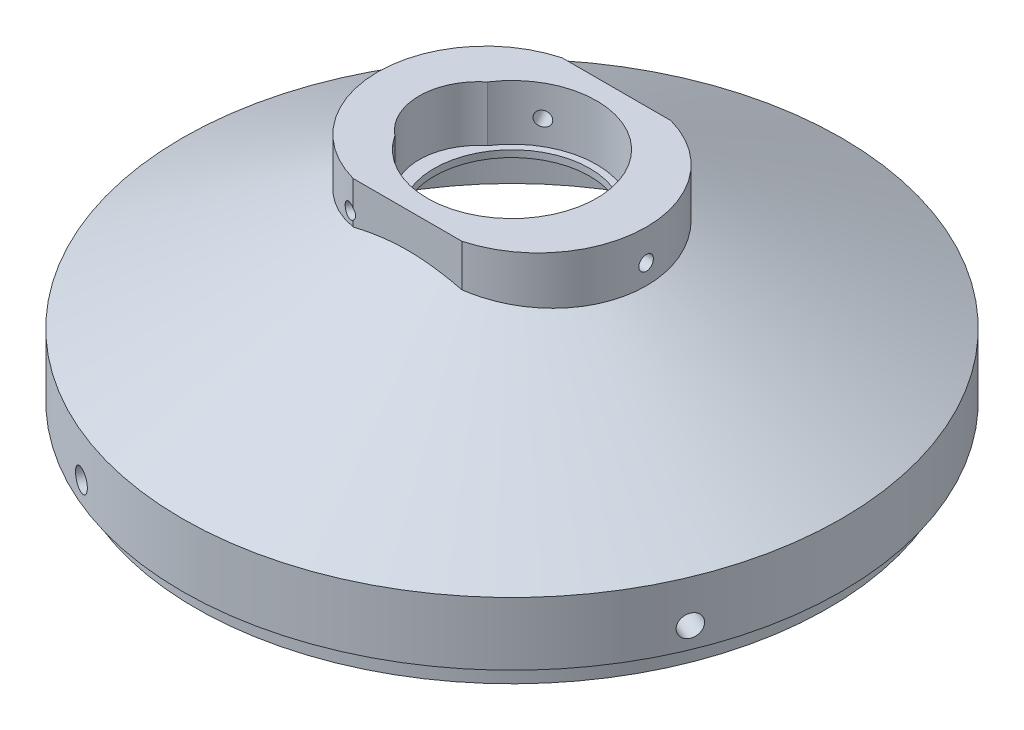
from build123d import *

# Parameters (mm, degrees)
SKETCH12_R          = 1.6425
CUT_EXTRUDE6_DEPTH  = 65.936179354
CUT_EXTRUDE7_REACH  = 38.04
SKETCH13_W          = 16.370705544
SKETCH13_H          = 2
BOSS_EXTRUDE1_REACH = 38.04
SKETCH14_R          = 12.75
CUT_EXTRUDE8_DEPTH  = 8.323317
SKETCH16_R          = 1.095
CUT_EXTRUDE9_DEPTH  = 50.7000001
CIRPATTERN2_COUNT   = 3
CIRPATTERN3_COUNT   = 4


with BuildPart() as part:
    # Sketch2 → Revolve1 (revolve)
    with BuildSketch(Plane.XY, mode=Mode.PRIVATE) as revolve1_sk:
        Polygon((49.7, 12.7), (49.7, 3.2004), (47.675, 3.2004), (47.675, 0), (44.7, 0), (44.7, 9.696683305), (12.75, 26.696683305), (11.73, 26.696683305), (11.73, 27.716683305), (12.75, 27.716683305), (12.75, 36.04), (17.75, 36.04), (17.75, 29.7), align=None)
    revolve(revolve1_sk.sketch.rotate(Axis((0, 0, 0), (0, 1, 0)), 90), axis=Axis((0, 0, 0), (0, 1, 0)))  # turned: the seam where the file's is

    # Sketch12 → Cut-Extrude6 (cut, through all)
    with BuildSketch(Plane(origin=(0, 0, 0), x_dir=(0.923879533, 0, 0.382683432), z_dir=(-0.382683432, 0, 0.923879533))):
        with Locations((0, 6.35)):
            Circle(SKETCH12_R)
    cut_extrude6 = extrude(amount=-CUT_EXTRUDE6_DEPTH, mode=Mode.SUBTRACT)

    # Cut-Extrude7: up to this cone (the profile starts outside it)
    cut_extrude7_end = Plane(origin=(0, 36.04, 0), z_dir=(0, -1, 0)).offset(-3.104443444) * Cone(1.879e-06, 89.232542042, 47.478972856, align=(Align.CENTER, Align.CENTER, Align.MIN), mode=Mode.PRIVATE)
    # Sketch13 → Cut-Extrude7 (cut, up to the surface)
    with BuildSketch(Plane(origin=(0, 36.04, 0), x_dir=(1, 0, 0), z_dir=(0, 1, 0)), mode=Mode.PRIVATE) as cut_extrude7_sk1:
        with Locations((0, 16.75)):
            Rectangle(SKETCH13_W, SKETCH13_H)
    cut_extrude7_tool1 = extrude(cut_extrude7_sk1.sketch, amount=-CUT_EXTRUDE7_REACH, mode=Mode.PRIVATE) - cut_extrude7_end
    add(cut_extrude7_tool1.solids().sort_by_distance((0, 36.04, -16.75))[0], mode=Mode.SUBTRACT)
    # Sketch13 → Cut-Extrude7 (cut, up to the surface)
    with BuildSketch(Plane(origin=(0, 36.04, 0), x_dir=(1, 0, 0), z_dir=(0, 1, 0)), mode=Mode.PRIVATE) as cut_extrude7_sk2:
        with Locations((0, -16.75)):
            Rectangle(SKETCH13_W, SKETCH13_H)
    cut_extrude7_tool2 = extrude(cut_extrude7_sk2.sketch, amount=-CUT_EXTRUDE7_REACH, mode=Mode.PRIVATE) - cut_extrude7_end
    add(cut_extrude7_tool2.solids().sort_by_distance((0, 36.04, 16.75))[0], mode=Mode.SUBTRACT)

    # Boss-Extrude1: up to this cone (the profile starts outside it)
    boss_extrude1_end = Plane(origin=(0, 36.04, 0), z_dir=(0, -1, 0)).offset(-3.104443444) * Cone(1.879e-06, 89.232542042, 47.478972856, align=(Align.CENTER, Align.CENTER, Align.MIN), mode=Mode.PRIVATE)
    # Sketch14 → Boss-Extrude1 (add, up to the surface)
    with BuildSketch(Plane(origin=(0, 36.04, 0), x_dir=(1, 0, 0), z_dir=(0, 1, 0)), mode=Mode.PRIVATE) as boss_extrude1_sk1:
        with BuildLine():
            Line((-8.185352772, 15.75), (8.185352772, 15.75))
            ThreePointArc((8.185352772, 15.75), (20.25, 0), (8.185352772, -15.75))
            Line((8.185352772, -15.75), (-8.185352772, -15.75))
            ThreePointArc((-8.185352772, -15.75), (-20.25, 0), (-8.185352772, 15.75))
        make_face()
        with Locations(Location((0, 0, 0), (0, 0, 90))):  # turned: the seam where the file's is
            Circle(SKETCH14_R, mode=Mode.SUBTRACT)
    boss_extrude1_tool1 = extrude(boss_extrude1_sk1.sketch, amount=-BOSS_EXTRUDE1_REACH, mode=Mode.PRIVATE) - boss_extrude1_end
    add(boss_extrude1_tool1.solids().sort_by_distance((0, 36.04, 15.236921))[0])

    # Sketch15 → Cut-Extrude8 (cut)
    with BuildSketch(Plane(origin=(0, 36.04, 0), x_dir=(1, 0, 0), z_dir=(0, 1, 0))):
        with BuildLine():
            ThreePointArc((-10.656570743, 7), (-13.999716493, 0), (-10.656570743, -7))
            ThreePointArc((-10.656570743, -7), (-12.75, 0), (-10.656570743, 7))
        make_face()
    extrude(amount=-CUT_EXTRUDE8_DEPTH, mode=Mode.SUBTRACT)

    # Sketch16 → Cut-Extrude9 (cut, through all)
    with BuildSketch(Plane(origin=(0, 0, 0), x_dir=(0, 0, -1), z_dir=(1, 0, 0))):
        with Locations(Location((0, 31.368341653, 0), (0, 0, 180))):  # turned: the seam where the file's is
            Circle(SKETCH16_R)
    cut_extrude9 = extrude(amount=CUT_EXTRUDE9_DEPTH, mode=Mode.SUBTRACT)

    # CirPattern2: Cut-Extrude9 ×3 about axis
    cirpattern2_axis = Axis((0, 13.335, 0), (0, -1, 0))
    for i in range(1, CIRPATTERN2_COUNT):
        add(cut_extrude9.rotate(cirpattern2_axis, i * 360 / CIRPATTERN2_COUNT), mode=Mode.SUBTRACT)

    # CirPattern3: Cut-Extrude6 ×4 about axis
    cirpattern3_axis = Axis((0, 13.335, 0), (0, -1, 0))
    for i in range(1, CIRPATTERN3_COUNT):
        add(cut_extrude6.rotate(cirpattern3_axis, i * 360 / CIRPATTERN3_COUNT), mode=Mode.SUBTRACT)


solid = part.part
